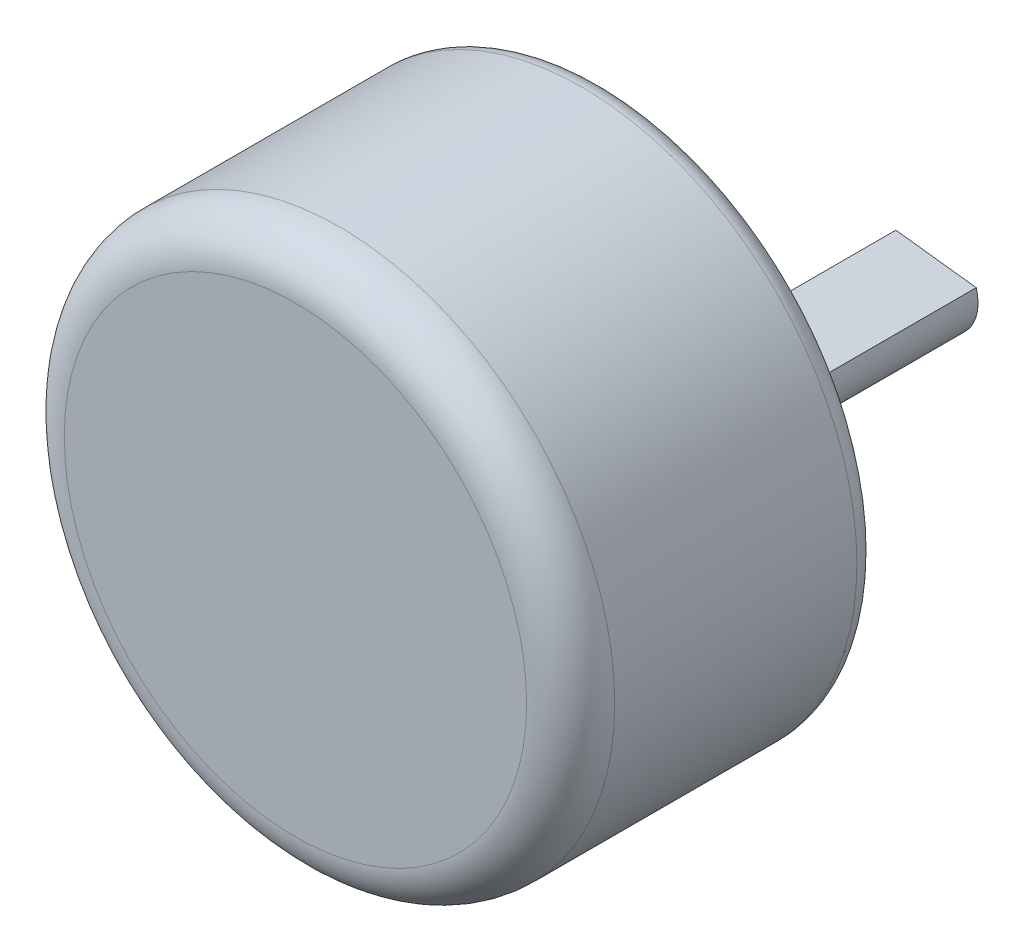
from build123d import *

# Parameters (mm, degrees)
SKETCH1_R               = 12.5
BOSS_EXTRUDE1_DEPTH     = 14
FILLET2_R               = 1
SKETCH6_R               = 1
CUT_EXTRUDE2_DEPTH      = 5
SKETCH7_R               = 4.25
BOSS_EXTRUDE5_DEPTH     = 3
FILLET4_R               = 0.5
SKETCH8_R               = 2
BOSS_EXTRUDE6_DEPTH     = 12
CUT_EXTRUDE3_DEPTH      = 1
CUT_EXTRUDE3_DEPTH_BACK = 9
FILLET5_R               = 2


with BuildPart() as part:
    # Sketch1 → Boss-Extrude1 (new body)
    with BuildSketch(Plane.XY):
        Circle(SKETCH1_R)
    extrude(amount=BOSS_EXTRUDE1_DEPTH)

    # Fillet2
    fillet2_edges = [part.edges().sort_by_distance(p)[0] for p in [
        (-12.5, 0, 0),
    ]]
    fillet(fillet2_edges, radius=FILLET2_R)

    # Sketch6 → Cut-Extrude2 (cut)
    with BuildSketch(Plane(origin=(0, 0, 0), x_dir=(-1, 0, 0), z_dir=(0, 0, -1))):
        with Locations((-9.5, 0)):
            Circle(SKETCH6_R)
        with Locations((9.5, 0)):
            Circle(SKETCH6_R)
    extrude(amount=-CUT_EXTRUDE2_DEPTH, mode=Mode.SUBTRACT)

    # Sketch7 → Boss-Extrude5 (add)
    with BuildSketch(Plane(origin=(0, 0, 0), x_dir=(-1, 0, 0), z_dir=(0, 0, -1))):
        with Locations((0, -3)):
            Circle(SKETCH7_R)
    extrude(amount=BOSS_EXTRUDE5_DEPTH)

    # Fillet4
    fillet4_edges = [part.edges().sort_by_distance(p)[0] for p in [
        (4.25, -3, -3),
    ]]
    fillet(fillet4_edges, radius=FILLET4_R)

    # Sketch8 → Boss-Extrude6 (add)
    with BuildSketch(Plane(origin=(0, 0, -3), x_dir=(-1, 0, 0), z_dir=(0, 0, -1))):
        with Locations((0, -3)):
            Circle(SKETCH8_R)
    extrude(amount=BOSS_EXTRUDE6_DEPTH)

    # Sketch9 → Cut-Extrude3 (cut, two sides)
    with BuildSketch(Plane(origin=(0, 0, -15), x_dir=(-1, 0, 0), z_dir=(0, 0, -1))) as cut_extrude3_sk:
        Polygon((-53.075925999, -8.559326208), (-1.919066235, -2.436808394), (1.731963356, -1.999848545), (52.88882312, 4.122669269), (40.643787491, 106.436388797), (-65.320961628, 93.754393319), align=None)
    extrude(amount=CUT_EXTRUDE3_DEPTH, mode=Mode.SUBTRACT)
    extrude(cut_extrude3_sk.sketch, amount=-CUT_EXTRUDE3_DEPTH_BACK, mode=Mode.SUBTRACT)

    # Fillet5
    fillet5_edges = [part.edges().sort_by_distance(p)[0] for p in [
        (-12.5, 0, 14),
    ]]
    fillet(fillet5_edges, radius=FILLET5_R)


solid = part.part
